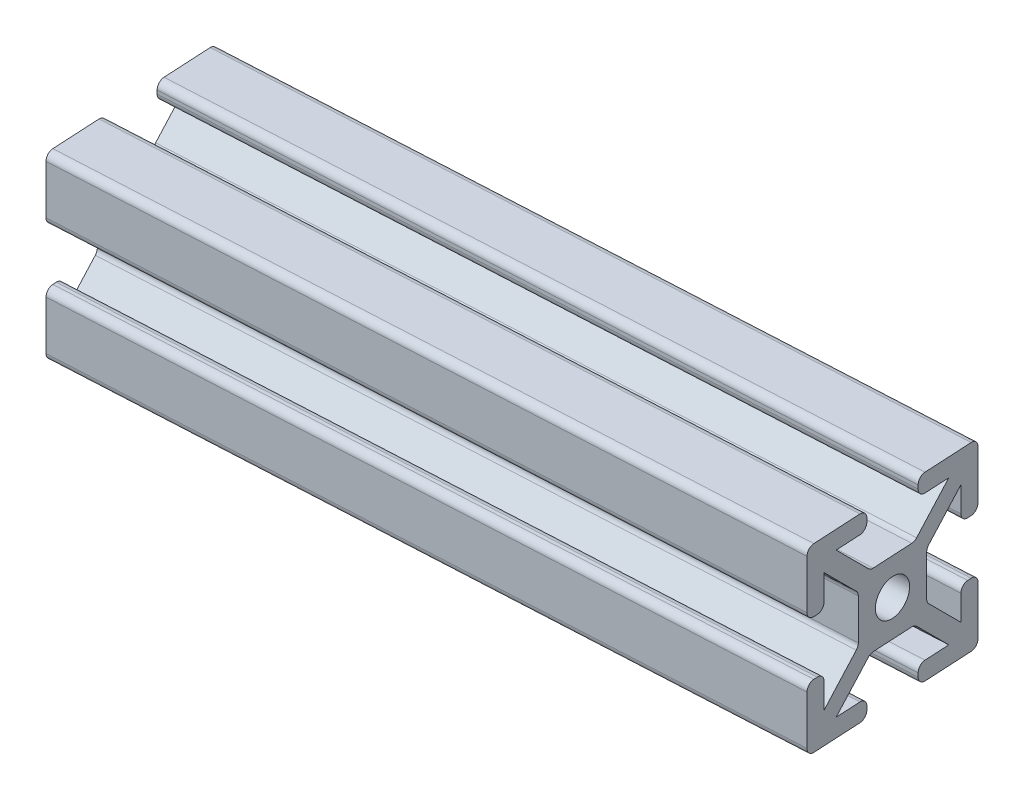
from build123d import *

# Parameters (mm, degrees)
SKETCH11_R       = 2
SIZE_4X4_1_DEPTH = 80


with BuildPart() as part:
    # Sketch11 → Size 4X4 (1) (new body)
    with BuildSketch(Plane(origin=(0, 0, 0), x_dir=(-0.05317143033370503, 0, -0.9985853989500688), z_dir=(0.9985853989500688, 0, -0.05317143033370503))):
        with BuildLine():
            Line((-3, 9.2), (-3, 8.8))
            ThreePointArc((-3, 8.8), (-3.234314575, 8.234314575), (-3.8, 8))
            Line((-3.8, 8), (-6.585786438, 8))
            Line((-6.585786438, 8), (-2.820101013, 4.234314575))
            ThreePointArc((-2.820101013, 4.234314575), (-2.560562334, 4.060896374), (-2.254415588, 4))
            Line((-2.254415588, 4), (2.254415588, 4))
            ThreePointArc((2.254415588, 4), (2.560562334, 4.060896374), (2.820101013, 4.234314575))
            Line((2.820101013, 4.234314575), (6.585786438, 8))
            Line((6.585786438, 8), (3.8, 8))
            ThreePointArc((3.8, 8), (3.234314575, 8.234314575), (3, 8.8))
            Line((3, 8.8), (3, 9.2))
            ThreePointArc((3, 9.2), (3.234314575, 9.765685425), (3.8, 10))
            Line((3.8, 10), (9.2, 10))
            ThreePointArc((9.2, 10), (9.765685425, 9.765685425), (10, 9.2))
            Line((10, 9.2), (10, 3.8))
            ThreePointArc((10, 3.8), (9.765685425, 3.234314575), (9.2, 3))
            Line((9.2, 3), (8.8, 3))
            ThreePointArc((8.8, 3), (8.234314575, 3.234314575), (8, 3.8))
            Line((8, 3.8), (8, 6.585786438))
            Line((8, 6.585786438), (4.234314575, 2.820101013))
            ThreePointArc((4.234314575, 2.820101013), (4.060896374, 2.560562334), (4, 2.254415588))
            Line((4, 2.254415588), (4, -2.254415588))
            ThreePointArc((4, -2.254415588), (4.060896374, -2.560562334), (4.234314575, -2.820101013))
            Line((4.234314575, -2.820101013), (8, -6.585786438))
            Line((8, -6.585786438), (8, -3.8))
            ThreePointArc((8, -3.8), (8.234314575, -3.234314575), (8.8, -3))
            Line((8.8, -3), (9.2, -3))
            ThreePointArc((9.2, -3), (9.765685425, -3.234314575), (10, -3.8))
            Line((10, -3.8), (10, -9.2))
            ThreePointArc((10, -9.2), (9.765685425, -9.765685425), (9.2, -10))
            Line((9.2, -10), (3.8, -10))
            ThreePointArc((3.8, -10), (3.234314575, -9.765685425), (3, -9.2))
            Line((3, -9.2), (3, -8.8))
            ThreePointArc((3, -8.8), (3.234314575, -8.234314575), (3.8, -8))
            Line((3.8, -8), (6.585786438, -8))
            Line((6.585786438, -8), (2.820101013, -4.234314575))
            ThreePointArc((2.820101013, -4.234314575), (2.560562334, -4.060896374), (2.254415588, -4))
            Line((2.254415588, -4), (-2.254415588, -4))
            ThreePointArc((-2.254415588, -4), (-2.560562334, -4.060896374), (-2.820101013, -4.234314575))
            Line((-2.820101013, -4.234314575), (-6.585786438, -8))
            Line((-6.585786438, -8), (-3.8, -8))
            ThreePointArc((-3.8, -8), (-3.234314575, -8.234314575), (-3, -8.8))
            Line((-3, -8.8), (-3, -9.2))
            ThreePointArc((-3, -9.2), (-3.234314575, -9.765685425), (-3.8, -10))
            Line((-3.8, -10), (-9.2, -10))
            ThreePointArc((-9.2, -10), (-9.765685425, -9.765685425), (-10, -9.2))
            Line((-10, -9.2), (-10, -3.8))
            ThreePointArc((-10, -3.8), (-9.765685425, -3.234314575), (-9.2, -3))
            Line((-9.2, -3), (-8.8, -3))
            ThreePointArc((-8.8, -3), (-8.234314575, -3.234314575), (-8, -3.8))
            Line((-8, -3.8), (-8, -6.585786438))
            Line((-8, -6.585786438), (-4.234314575, -2.820101013))
            ThreePointArc((-4.234314575, -2.820101013), (-4.060896374, -2.560562334), (-4, -2.254415588))
            Line((-4, -2.254415588), (-4, 2.254415588))
            ThreePointArc((-4, 2.254415588), (-4.060896374, 2.560562334), (-4.234314575, 2.820101013))
            Line((-4.234314575, 2.820101013), (-8, 6.585786438))
            Line((-8, 6.585786438), (-8, 3.8))
            ThreePointArc((-8, 3.8), (-8.234314575, 3.234314575), (-8.8, 3))
            Line((-8.8, 3), (-9.2, 3))
            ThreePointArc((-9.2, 3), (-9.765685425, 3.234314575), (-10, 3.8))
            Line((-10, 3.8), (-10, 9.2))
            ThreePointArc((-10, 9.2), (-9.765685425, 9.765685425), (-9.2, 10))
            Line((-9.2, 10), (-3.8, 10))
            ThreePointArc((-3.8, 10), (-3.234314575, 9.765685425), (-3, 9.2))
        make_face()
        Circle(SKETCH11_R, mode=Mode.SUBTRACT)
    extrude(amount=SIZE_4X4_1_DEPTH)


solid = part.part
